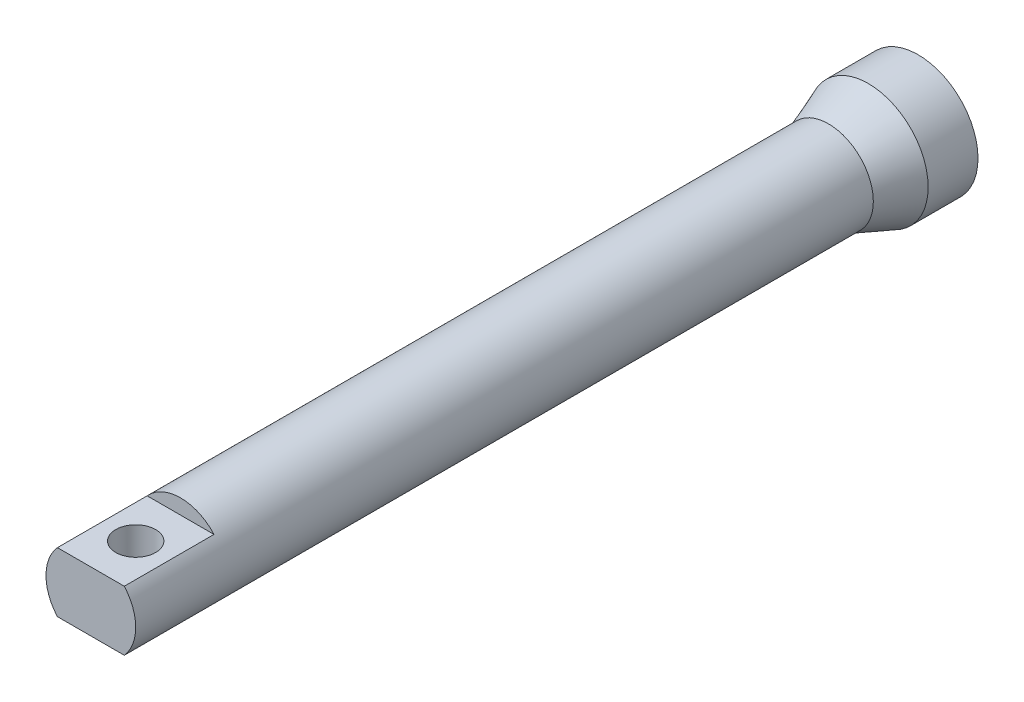
from build123d import *

# Parameters (mm, degrees)
SKETCH3_R               = 22.5
SKETCH3_R_2             = 17.5
BOSS_EXTRUDE1_DEPTH     = 320
SKETCH4_R               = 22.5
BOSS_EXTRUDE2_DEPTH     = 50
SKETCH5_W               = 33.541019662
SKETCH5_H               = 20
CUT_EXTRUDE1_DEPTH      = 45
SKETCH6_R               = 10
CUT_EXTRUDE3_DEPTH      = 16
CUT_EXTRUDE3_DEPTH_BACK = 46


with BuildPart() as part:
    # Sketch2 → Revolve1 (revolve)
    with BuildSketch(Plane(origin=(0, 0, 0), x_dir=(1, 0, 0), z_dir=(0, 1, 0))):
        Polygon((-30, 0), (-30, -25), (-22.5, -45), (-17.5, -45), (-25, -25), (-25, 0), align=None)
    revolve(axis=Axis((0, 0, 47.25), (0, 0, -1)))

    # Sketch3 → Boss-Extrude1 (add)
    with BuildSketch(Plane.XY.offset(45)):
        Circle(SKETCH3_R)
        Circle(SKETCH3_R_2, mode=Mode.SUBTRACT)
    extrude(amount=BOSS_EXTRUDE1_DEPTH)

    # Sketch4 → Boss-Extrude2 (add)
    with BuildSketch(Plane.XY.offset(365)):
        Circle(SKETCH4_R)
    extrude(amount=BOSS_EXTRUDE2_DEPTH)

    # Sketch5 → Cut-Extrude1 (cut)
    with BuildSketch(Plane.XY.offset(415)):
        with Locations((0, 25)):
            Rectangle(SKETCH5_W, SKETCH5_H)
        with Locations((0, -25)):
            Rectangle(SKETCH5_W, SKETCH5_H)
    extrude(amount=-CUT_EXTRUDE1_DEPTH, mode=Mode.SUBTRACT)

    # Sketch6 → Cut-Extrude3 (cut, two sides)
    with BuildSketch(Plane(origin=(0, 15, 0), x_dir=(1, 0, 0), z_dir=(0, 1, 0))) as cut_extrude3_sk:
        with Locations((0, -392.5)):
            Circle(SKETCH6_R)
    extrude(amount=CUT_EXTRUDE3_DEPTH, mode=Mode.SUBTRACT)
    extrude(cut_extrude3_sk.sketch, amount=-CUT_EXTRUDE3_DEPTH_BACK, mode=Mode.SUBTRACT)


solid = part.part
